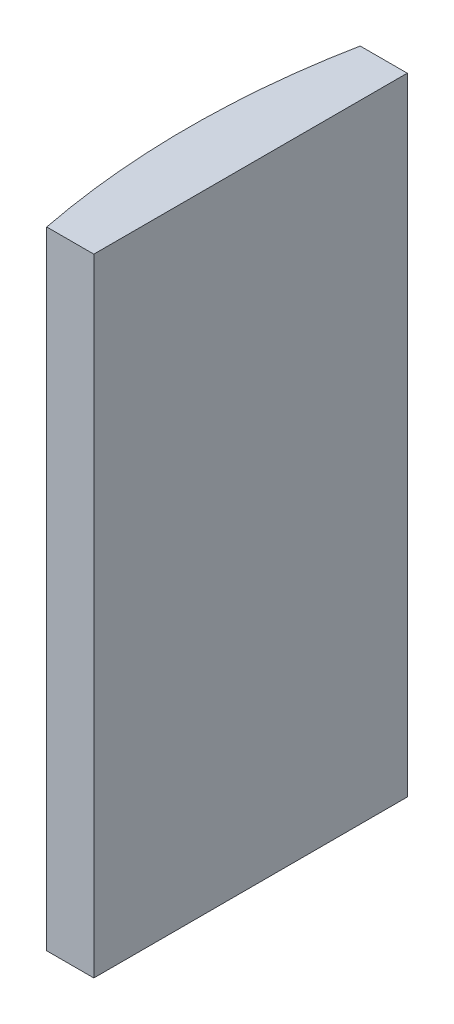
from build123d import *

# Parameters (mm, degrees)
EXTRUDE_1_DEPTH = 40


with BuildPart() as part:
    # 草图1 → 凸台-拉伸1 (new body)
    with BuildSketch(Plane(origin=(0, 0, 0), x_dir=(1, 0, 0), z_dir=(0, 1, 0))):
        with BuildLine():
            Line((-46.348073666, 10), (-43.344795665, 10))
            Line((-43.344795665, 10), (-43.344795665, -10))
            Line((-43.344795665, -10), (-46.348073666, -10))
            ThreePointArc((-46.348073666, -10), (-47.324795665, 0), (-46.348073666, 10))
        make_face()
    extrude(amount=EXTRUDE_1_DEPTH)


solid = part.part
